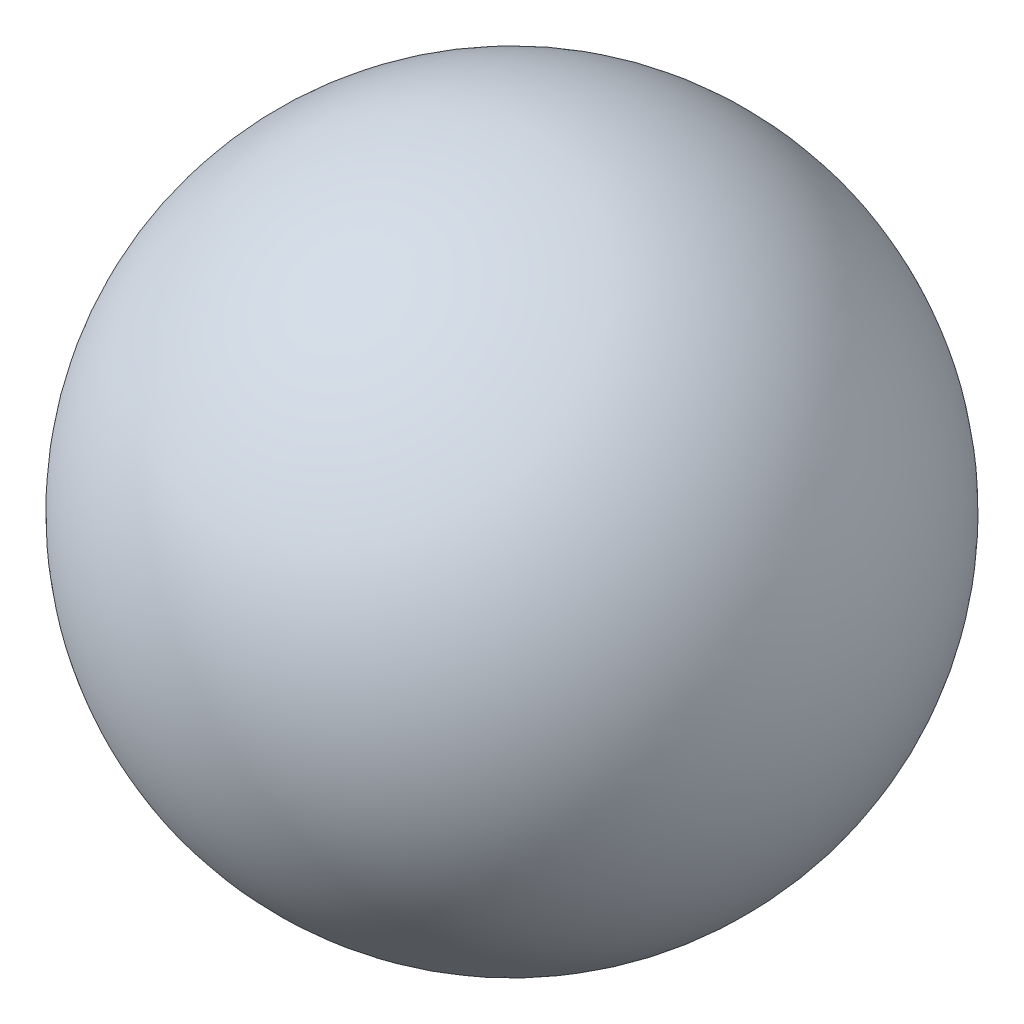
from build123d import *


with BuildPart() as part:
    # Sketch1 → Revolve1 (revolve)
    with BuildSketch(Plane(origin=(0, 0, 0), x_dir=(1, 0, 0), z_dir=(0, 1, 0))):
        with BuildLine():
            Line((0, 8.2), (0, -8.2))
            ThreePointArc((0, -8.2), (8.2, 0), (0, 8.2))
        make_face()
    revolve(axis=Axis((0, 0, -8.2), (0, 0, 1)))


solid = part.part
